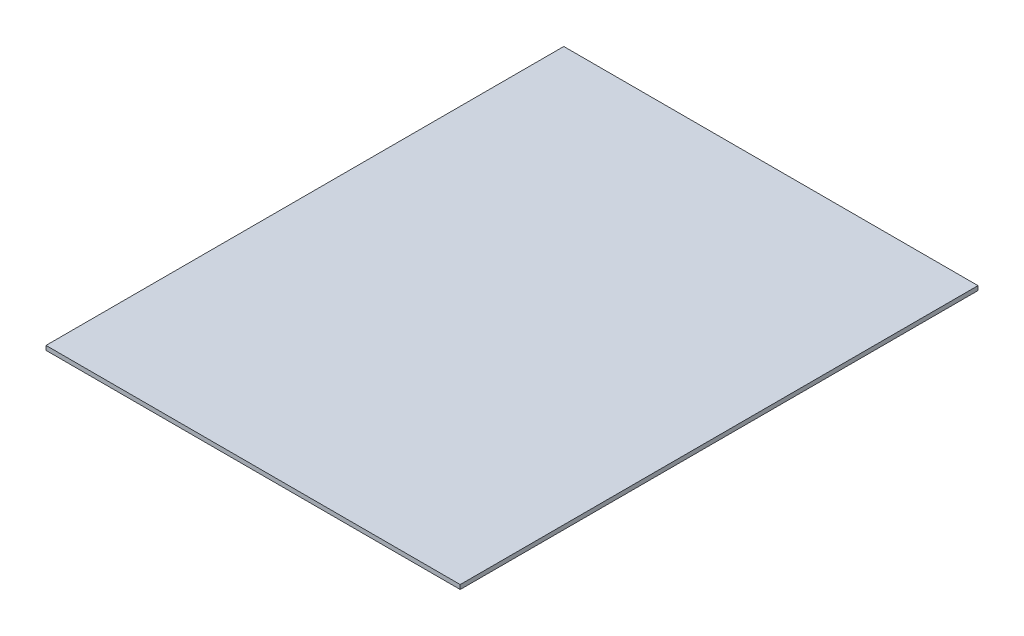
from build123d import *

# Parameters (mm, degrees)
SKETCH1_W           = 609.6
SKETCH1_H           = 762
BOSS_EXTRUDE1_DEPTH = 6.35


with BuildPart() as part:
    # Sketch1 → Boss-Extrude1 (new body)
    with BuildSketch(Plane(origin=(0, 0, 0), x_dir=(1, 0, 0), z_dir=(0, 1, 0))):
        with Locations((304.8, 381)):
            Rectangle(SKETCH1_W, SKETCH1_H)
    extrude(amount=BOSS_EXTRUDE1_DEPTH)


solid = part.part
